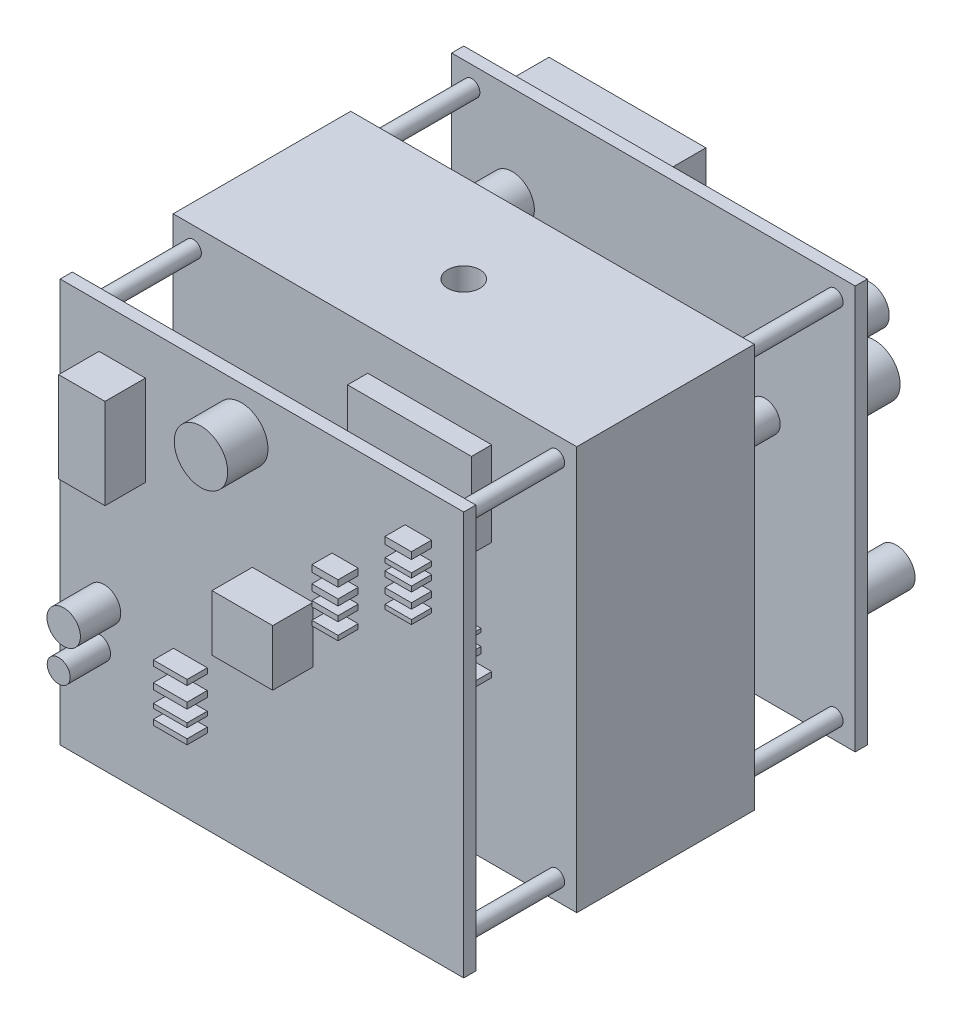
from build123d import *

# Parameters (mm, degrees)
CROQUIS1_W               = 100
CROQUIS1_H               = 100
SALIENTE_EXTRUIR1_DEPTH  = 100
CROQUIS2_W               = 25
CROQUIS2_H               = 100
CORTAR_EXTRUIR1_DEPTH    = 100
CROQUIS3_R               = 4
CORTAR_EXTRUIR2_DEPTH    = 100
CROQUIS4_R               = 2
SALIENTE_EXTRUIR2_DEPTH  = 100
CROQUIS5_W               = 28.014963793
CROQUIS5_H               = 9.051812895
CROQUIS5_W_2             = 2.954560647
CROQUIS5_W_3             = 3.39657131
CROQUIS5_W_4             = 2.705494987
CROQUIS5_W_5             = 11.571132933
CROQUIS5_H_2             = 11.097873227
SALIENTE_EXTRUIR3_DEPTH  = 5
CROQUIS6_R               = 3.840531475
CROQUIS6_R_2             = 4.686080108
SALIENTE_EXTRUIR4_DEPTH  = 15
CROQUIS7_W               = 38.87912129
CROQUIS7_H               = 26.349323358
SALIENTE_EXTRUIR5_DEPTH  = 15
CROQUIS9_R               = 4.785044561
CROQUIS9_R_2             = 6.367870478
CROQUIS9_R_3             = 2.466912166
SALIENTE_EXTRUIR7_DEPTH  = 10
CROQUIS10_R              = 5.793086174
CROQUIS10_R_2            = 2.31809738
CROQUIS10_R_3            = 5.48706726
CROQUIS10_R_4            = 3.763310936
CROQUIS10_W              = 32.541145419
CROQUIS10_H              = 7.810522345
CROQUIS10_W_2            = 51.521675343
CROQUIS10_H_2            = 23.571567841
SALIENTE_EXTRUIR8_DEPTH  = 10
CROQUIS11_R              = 6.618616789
CROQUIS11_R_2            = 4.139609283
CROQUIS11_R_3            = 2.844513546
CROQUIS11_W              = 11.477012866
CROQUIS11_H              = 22.393691404
CROQUIS11_W_2            = 15.030927027
CROQUIS11_H_2            = 13.868299131
SALIENTE_EXTRUIR9_DEPTH  = 10
CROQUIS12_W              = 8.359310308
CROQUIS12_H              = 1.309360747
CROQUIS12_H_2            = 1.067105011
CROQUIS12_H_3            = 1.50693684
CROQUIS12_H_4            = 1.336617059
SALIENTE_EXTRUIR12_DEPTH = 5
CROQUIS13_W              = 6.56197319
CROQUIS13_H              = 1.705437116
CROQUIS13_H_2            = 1.130487953
CROQUIS13_H_3            = 1.287425288
CROQUIS13_H_4            = 1.401382976
CROQUIS13_H_5            = 1.087508306
CROQUIS13_W_2            = 6.487517882
CROQUIS13_H_6            = 1.626101739
CROQUIS13_H_7            = 1.54333906
CROQUIS13_H_8            = 1.322914308
CROQUIS13_H_9            = 1.1734676
SALIENTE_EXTRUIR13_DEPTH = 5
CROQUIS14_W              = 30.712185141
CROQUIS14_H              = 20.943922245
CROQUIS14_W_2            = 19.421800597
CROQUIS14_H_2            = 1.175823789
CROQUIS14_W_3            = 20.78262229
CROQUIS14_H_3            = 1.282192639
CROQUIS14_W_4            = 20.500354159
CROQUIS14_H_4            = 0.874412394
CROQUIS14_W_5            = 18.507472387
CROQUIS14_H_5            = 1.583604033
CROQUIS14_W_6            = 21.149419091
CROQUIS14_H_6            = 1.323547308
SALIENTE_EXTRUIR14_DEPTH = 5


with BuildPart() as part:
    # Croquis1 → Saliente-Extruir1 (new body)
    with BuildSketch(Plane(origin=(0, 0, 0), x_dir=(1, 0, 0), z_dir=(0, 1, 0))):
        with Locations((50, 50)):
            Rectangle(CROQUIS1_W, CROQUIS1_H)
    extrude(amount=SALIENTE_EXTRUIR1_DEPTH)

    # Croquis2 → Cortar-Extruir1 (cut)
    with BuildSketch(Plane(origin=(100, 0, 0), x_dir=(0, 0, -1), z_dir=(1, 0, 0))):
        with Locations((15.5, 50)):
            Rectangle(CROQUIS2_W, CROQUIS2_H)
        with Locations((84.5, 50)):
            Rectangle(CROQUIS2_W, CROQUIS2_H)
    extrude(amount=-CORTAR_EXTRUIR1_DEPTH, mode=Mode.SUBTRACT)

    # Croquis3 → Cortar-Extruir2 (cut)
    with BuildSketch(Plane(origin=(0, 100, 0), x_dir=(1, 0, 0), z_dir=(0, 1, 0))):
        with Locations((50, 50)):
            Circle(CROQUIS3_R)
    extrude(amount=-CORTAR_EXTRUIR2_DEPTH, mode=Mode.SUBTRACT)

    # Croquis4 → Saliente-Extruir2 (add)
    with BuildSketch(Plane(origin=(0, 0, -100), x_dir=(-1, 0, 0), z_dir=(0, 0, -1))):
        with Locations((-95, 95)):
            Circle(CROQUIS4_R)
        with Locations((-95, 5.03405208)):
            Circle(CROQUIS4_R)
        with Locations((-5, 95)):
            Circle(CROQUIS4_R)
        with Locations((-5, 5.03405208)):
            Circle(CROQUIS4_R)
    extrude(amount=-SALIENTE_EXTRUIR2_DEPTH)

    # Croquis5 → Saliente-Extruir3 (add)
    with BuildSketch(Plane(origin=(0, 0, -100), x_dir=(-1, 0, 0), z_dir=(0, 0, -1))):
        with Locations((-23.635184558, 12.112124115)):
            Rectangle(CROQUIS5_W, CROQUIS5_H)
        with Locations((-52.541553902, 12.112124115)):
            Rectangle(CROQUIS5_W_2, CROQUIS5_H)
        with Locations((-59.50170842, 12.112124115)):
            Rectangle(CROQUIS5_W_3, CROQUIS5_H)
        with Locations((-73.987801173, 12.112124115)):
            Rectangle(CROQUIS5_W_4, CROQUIS5_H)
        with Locations((-58.32712037, 48.743140543)):
            Rectangle(CROQUIS5_W_5, CROQUIS5_H_2)
    extrude(amount=SALIENTE_EXTRUIR3_DEPTH)

    # Croquis6 → Saliente-Extruir4 (add)
    with BuildSketch(Plane(origin=(0, 0, -100), x_dir=(-1, 0, 0), z_dir=(0, 0, -1))):
        with Locations((-13.664728634, 30.653502261)):
            Circle(CROQUIS6_R)
        with Locations((-92.1488144, 26.812970786)):
            Circle(CROQUIS6_R_2)
    extrude(amount=SALIENTE_EXTRUIR4_DEPTH)

    # Croquis7 → Saliente-Extruir5 (add)
    with BuildSketch(Plane(origin=(0, 0, -100), x_dir=(-1, 0, 0), z_dir=(0, 0, -1))):
        with Locations((-25.561971547, 79.979772745)):
            Rectangle(CROQUIS7_W, CROQUIS7_H)
    extrude(amount=SALIENTE_EXTRUIR5_DEPTH)

    # Croquis9 → Saliente-Extruir7 (add)
    with BuildSketch(Plane(origin=(0, 0, -100), x_dir=(-1, 0, 0), z_dir=(0, 0, -1))):
        with Locations((-90.660928356, 84.874198192)):
            Circle(CROQUIS9_R)
        with Locations((-91.763562846, 71.404974806)):
            Circle(CROQUIS9_R_2)
        with Locations((-80.514248765, 84.874198192)):
            Circle(CROQUIS9_R_3)
    extrude(amount=SALIENTE_EXTRUIR7_DEPTH)

    # Croquis10 → Saliente-Extruir8 (add)
    with BuildSketch(Plane(origin=(0, 0, -72), x_dir=(-1, 0, 0), z_dir=(0, 0, -1))):
        with Locations((-82.051886177, 25.231528411)):
            Circle(CROQUIS10_R)
        with Locations((-14.982847097, 87.088662407)):
            Circle(CROQUIS10_R_2)
        with Locations((-30.0148444, 91.575948126)):
            Circle(CROQUIS10_R_3)
        with Locations((-92.648427406, 75.96536285)):
            Circle(CROQUIS10_R_4)
        with Locations((-46.28541711, 73.951827076)):
            Rectangle(CROQUIS10_W, CROQUIS10_H)
        with Locations((-49.06617746, 44.981737468)):
            Rectangle(CROQUIS10_W_2, CROQUIS10_H_2)
    extrude(amount=SALIENTE_EXTRUIR8_DEPTH)

    # Croquis11 → Saliente-Extruir9 (add)
    with BuildSketch(Plane.XY):
        with Locations((44.886334375, 89.290075512)):
            Circle(CROQUIS11_R)
        with Locations((10.869565611, 35.747288597)):
            Circle(CROQUIS11_R_2)
        with Locations((9.632332503, 25.754447062)):
            Circle(CROQUIS11_R_3)
        with Locations((15.370838936, 78.09322981)):
            Rectangle(CROQUIS11_W, CROQUIS11_H)
        with Locations((55.139514231, 55.011152001)):
            Rectangle(CROQUIS11_W_2, CROQUIS11_H_2)
    extrude(amount=SALIENTE_EXTRUIR9_DEPTH)

    # Croquis12 → Saliente-Extruir12 (add)
    with BuildSketch(Plane.XY):
        with Locations((32.266668911, 21.407969294)):
            Rectangle(CROQUIS12_W, CROQUIS12_H)
        with Locations((32.266668911, 24.947933784)):
            Rectangle(CROQUIS12_W, CROQUIS12_H_2)
        with Locations((32.266668911, 29.162648826)):
            Rectangle(CROQUIS12_W, CROQUIS12_H_3)
        with Locations((32.266668911, 34.127920992)):
            Rectangle(CROQUIS12_W, CROQUIS12_H_4)
    extrude(amount=SALIENTE_EXTRUIR12_DEPTH)

    # Croquis13 → Saliente-Extruir13 (add)
    with BuildSketch(Plane.XY):
        with Locations((88.754333095, 89.142527072)):
            Rectangle(CROQUIS13_W, CROQUIS13_H)
        with Locations((88.754333095, 84.881148844)):
            Rectangle(CROQUIS13_W, CROQUIS13_H_2)
        with Locations((88.754333095, 81.966755107)):
            Rectangle(CROQUIS13_W, CROQUIS13_H_3)
        with Locations((88.754333095, 78.33963479)):
            Rectangle(CROQUIS13_W, CROQUIS13_H_4)
        with Locations((88.754333095, 74.883451007)):
            Rectangle(CROQUIS13_W, CROQUIS13_H_5)
        with Locations((70.610389752, 74.070400138)):
            Rectangle(CROQUIS13_W_2, CROQUIS13_H_6)
        with Locations((70.610389752, 70.003046572)):
            Rectangle(CROQUIS13_W_2, CROQUIS13_H_7)
        with Locations((70.610389752, 66.51511908)):
            Rectangle(CROQUIS13_W_2, CROQUIS13_H_8)
        with Locations((70.610389752, 62.363953227)):
            Rectangle(CROQUIS13_W_2, CROQUIS13_H_9)
    extrude(amount=SALIENTE_EXTRUIR13_DEPTH)

    # Croquis14 → Saliente-Extruir14 (add)
    with BuildSketch(Plane.XY.offset(-28)):
        with Locations((63.563993269, 79.414556202)):
            Rectangle(CROQUIS14_W, CROQUIS14_H)
        with Locations((63.845595451, 56.428453676)):
            Rectangle(CROQUIS14_W_2, CROQUIS14_H_2)
        with Locations((64.526006297, 52.711211406)):
            Rectangle(CROQUIS14_W_3, CROQUIS14_H_3)
        with Locations((66.027962056, 48.736894588)):
            Rectangle(CROQUIS14_W_4, CROQUIS14_H_4)
        with Locations((67.024402941, 44.505503223)):
            Rectangle(CROQUIS14_W_5, CROQUIS14_H_5)
        with Locations((68.345376294, 40.563693497)):
            Rectangle(CROQUIS14_W_6, CROQUIS14_H_6)
    extrude(amount=SALIENTE_EXTRUIR14_DEPTH)


solid = part.part
